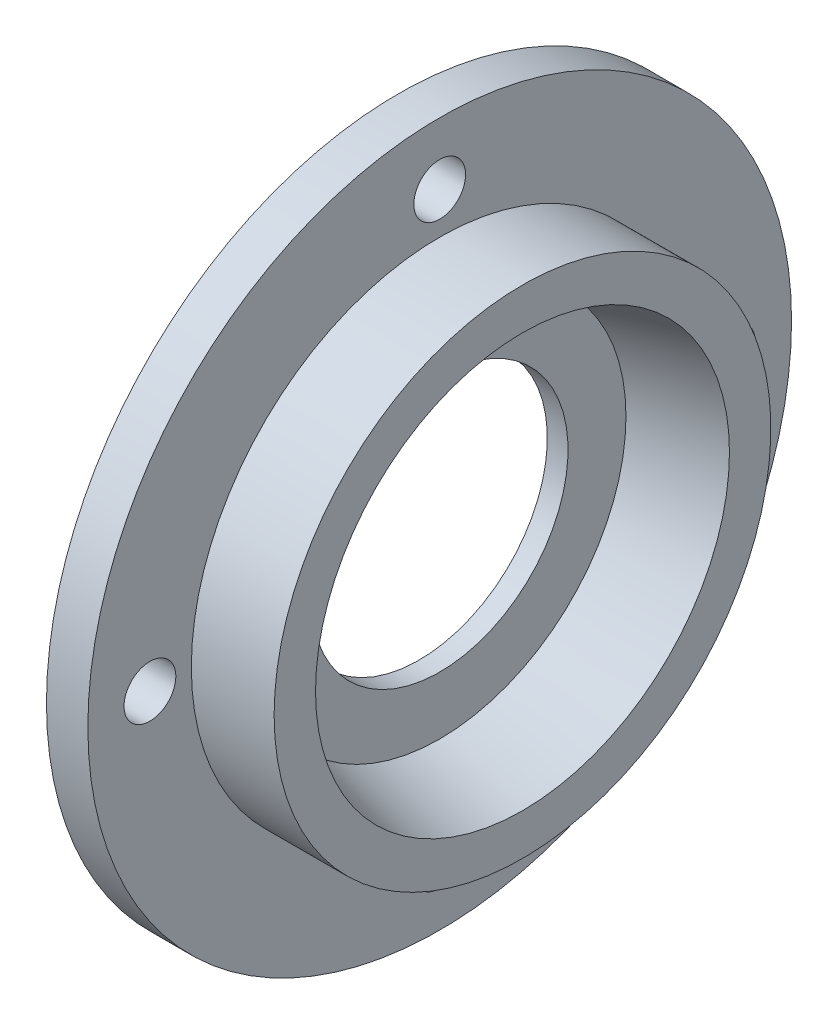
from build123d import *

# Parameters (mm, degrees)
CUT_EXTRUDE3_REACH = 8
SKETCH4_R          = 1.25
SKETCH2_R          = 12
CUT_EXTRUDE4_DEPTH = 1
CUT_EXTRUDE5_REACH = 7
SKETCH5_R          = 6.2


with BuildPart() as part:
    # Sketch1 → Revolve1 (revolve)
    with BuildSketch(Plane.XY):
        Polygon((0, 0), (0, 17), (2, 17), (2, 12), (6, 12), (6, 10), (2, 9), (2, 0), align=None)
    revolve(axis=Axis((0, 0, 0), (1, 0, 0)))

    # Sketch4 → Cut-Extrude3 (cut, up to next)
    with BuildSketch(Plane.ZY, mode=Mode.PRIVATE) as cut_extrude3_sk1:
        with Locations((0, 14)):
            Circle(SKETCH4_R)
    cut_extrude3_tool1 = extrude(cut_extrude3_sk1.sketch, amount=-CUT_EXTRUDE3_REACH, mode=Mode.PRIVATE) & part.part
    add(cut_extrude3_tool1.solids().sort_by_distance((0, 14, 0))[0], mode=Mode.SUBTRACT)
    # Sketch4 → Cut-Extrude3 (cut, up to next)
    with BuildSketch(Plane.ZY, mode=Mode.PRIVATE) as cut_extrude3_sk2:
        with Locations((14, 0)):
            Circle(SKETCH4_R)
    cut_extrude3_tool2 = extrude(cut_extrude3_sk2.sketch, amount=-CUT_EXTRUDE3_REACH, mode=Mode.PRIVATE) & part.part
    add(cut_extrude3_tool2.solids().sort_by_distance((0, 0, 14))[0], mode=Mode.SUBTRACT)
    # Sketch4 → Cut-Extrude3 (cut, up to next)
    with BuildSketch(Plane.ZY, mode=Mode.PRIVATE) as cut_extrude3_sk3:
        with Locations((0, -14)):
            Circle(SKETCH4_R)
    cut_extrude3_tool3 = extrude(cut_extrude3_sk3.sketch, amount=-CUT_EXTRUDE3_REACH, mode=Mode.PRIVATE) & part.part
    add(cut_extrude3_tool3.solids().sort_by_distance((0, -14, 0))[0], mode=Mode.SUBTRACT)
    # Sketch4 → Cut-Extrude3 (cut, up to next)
    with BuildSketch(Plane.ZY, mode=Mode.PRIVATE) as cut_extrude3_sk4:
        with Locations((-14, 0)):
            Circle(SKETCH4_R)
    cut_extrude3_tool4 = extrude(cut_extrude3_sk4.sketch, amount=-CUT_EXTRUDE3_REACH, mode=Mode.PRIVATE) & part.part
    add(cut_extrude3_tool4.solids().sort_by_distance((0, 0, -14))[0], mode=Mode.SUBTRACT)

    # Sketch2 → Cut-Extrude4 (cut)
    with BuildSketch(Plane.ZY):
        Circle(SKETCH2_R)
    extrude(amount=-CUT_EXTRUDE4_DEPTH, mode=Mode.SUBTRACT)

    # Sketch5 → Cut-Extrude5 (cut, up to next)
    with BuildSketch(Plane.ZY.offset(-1), mode=Mode.PRIVATE) as cut_extrude5_sk1:
        Circle(SKETCH5_R)
    cut_extrude5_tool1 = extrude(cut_extrude5_sk1.sketch, amount=-CUT_EXTRUDE5_REACH, mode=Mode.PRIVATE) & part.part
    add(cut_extrude5_tool1.solids().sort_by_distance((1, 0, 0))[0], mode=Mode.SUBTRACT)


solid = part.part
